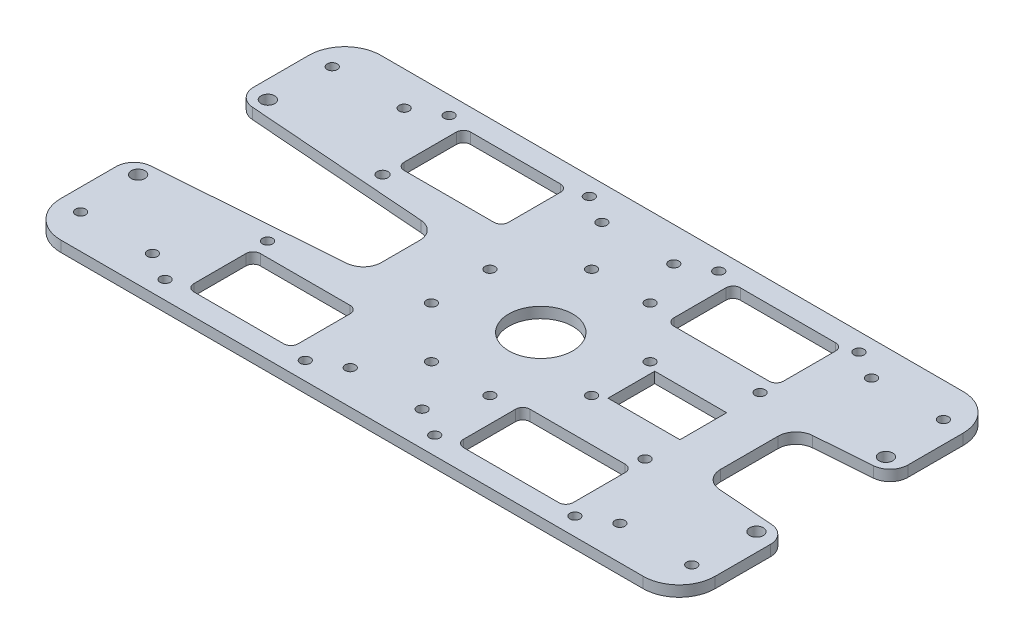
from build123d import *

# Parameters (mm, degrees)
SKETCH1_R           = 8.9
SKETCH1_R_2         = 1.9
SKETCH1_R_3         = 1.4
SKETCH1_R_4         = 1.5
SKETCH1_W           = 20
SKETCH1_H           = 13
BOSS_EXTRUDE1_DEPTH = 3


with BuildPart() as part:
    # Sketch1 → Boss-Extrude1 (new body)
    with BuildSketch(Plane(origin=(0, 0, 0), x_dir=(1, 0, 0), z_dir=(0, 1, 0))):
        with BuildLine():
            Line((78.373949741, -14.153046231), (62.626050259, -12.971953769))
            ThreePointArc((62.626050259, -12.971953769), (59.334638578, -11.386710908), (58, -7.98595722))
            Line((58, -7.98595722), (58, 7.98595722))
            ThreePointArc((58, 7.98595722), (59.334638578, 11.386710908), (62.626050259, 12.971953769))
            Line((62.626050259, 12.971953769), (78.373949741, 14.153046231))
            ThreePointArc((78.373949741, 14.153046231), (81.665361422, 15.738289092), (83, 19.13904278))
            Line((83, 19.13904278), (83, 34.5))
            ThreePointArc((83, 34.5), (80.071067812, 41.571067812), (73, 44.5))
            Line((73, 44.5), (-89, 44.5))
            ThreePointArc((-89, 44.5), (-96.071067812, 41.571067812), (-99, 34.5))
            Line((-99, 34.5), (-99, 19.13904278))
            ThreePointArc((-99, 19.13904278), (-97.665361422, 15.738289092), (-94.373949741, 14.153046231))
            Line((-94.373949741, 14.153046231), (-43.626050259, 10.346953769))
            ThreePointArc((-43.626050259, 10.346953769), (-40.334638578, 8.761710908), (-39, 5.36095722))
            Line((-39, 5.36095722), (-39, -5.36095722))
            ThreePointArc((-39, -5.36095722), (-40.334638578, -8.761710908), (-43.626050259, -10.346953769))
            Line((-43.626050259, -10.346953769), (-94.373949741, -14.153046231))
            ThreePointArc((-94.373949741, -14.153046231), (-97.665361422, -15.738289092), (-99, -19.13904278))
            Line((-99, -19.13904278), (-99, -34.5))
            ThreePointArc((-99, -34.5), (-96.071067812, -41.571067812), (-89, -44.5))
            Line((-89, -44.5), (73, -44.5))
            ThreePointArc((73, -44.5), (80.071067812, -41.571067812), (83, -34.5))
            Line((83, -34.5), (83, -19.13904278))
            ThreePointArc((83, -19.13904278), (81.665361422, -15.738289092), (78.373949741, -14.153046231))
        make_face()
        Circle(SKETCH1_R, mode=Mode.SUBTRACT)
        with Locations((78, -18)):
            Circle(SKETCH1_R_2, mode=Mode.SUBTRACT)
        with Locations((77, -35)):
            Circle(SKETCH1_R_3, mode=Mode.SUBTRACT)
        with Locations((57, -35)):
            Circle(SKETCH1_R_3, mode=Mode.SUBTRACT)
        with Locations((49, -39.5)):
            Circle(SKETCH1_R_3, mode=Mode.SUBTRACT)
        with Locations((45, -16)):
            Circle(SKETCH1_R_3, mode=Mode.SUBTRACT)
        with Locations((22.273863607, -8.131727984)):
            Circle(SKETCH1_R_3, mode=Mode.SUBTRACT)
        with Locations((22.273863607, 8.131727984)):
            Circle(SKETCH1_R_3, mode=Mode.SUBTRACT)
        with Locations((10, -39.5)):
            Circle(SKETCH1_R_3, mode=Mode.SUBTRACT)
        with Locations((2, -35)):
            Circle(SKETCH1_R_3, mode=Mode.SUBTRACT)
        with Locations((8.131727984, -22.273863607)):
            Circle(SKETCH1_R_3, mode=Mode.SUBTRACT)
        with Locations((-8.131727984, -22.273863607)):
            Circle(SKETCH1_R_3, mode=Mode.SUBTRACT)
        with Locations((-18, -35)):
            Circle(SKETCH1_R_3, mode=Mode.SUBTRACT)
        with Locations((-26, -39.5)):
            Circle(SKETCH1_R_3, mode=Mode.SUBTRACT)
        with Locations((-22.273863607, -8.131727984)):
            Circle(SKETCH1_R_3, mode=Mode.SUBTRACT)
        with Locations((-22.273863607, 8.131727984)):
            Circle(SKETCH1_R_3, mode=Mode.SUBTRACT)
        with Locations((-8.131727984, 22.273863607)):
            Circle(SKETCH1_R_3, mode=Mode.SUBTRACT)
        with Locations((8.131727984, 22.273863607)):
            Circle(SKETCH1_R_3, mode=Mode.SUBTRACT)
        with Locations((45, 16)):
            Circle(SKETCH1_R_3, mode=Mode.SUBTRACT)
        with Locations((78, 18)):
            Circle(SKETCH1_R_2, mode=Mode.SUBTRACT)
        with Locations((77, 35)):
            Circle(SKETCH1_R_3, mode=Mode.SUBTRACT)
        with Locations((57, 35)):
            Circle(SKETCH1_R_3, mode=Mode.SUBTRACT)
        with Locations((49, 39.5)):
            Circle(SKETCH1_R_3, mode=Mode.SUBTRACT)
        with Locations((10, 39.5)):
            Circle(SKETCH1_R_3, mode=Mode.SUBTRACT)
        with Locations((2, 35)):
            Circle(SKETCH1_R_3, mode=Mode.SUBTRACT)
        with Locations((-18, 35)):
            Circle(SKETCH1_R_3, mode=Mode.SUBTRACT)
        with Locations((-26, 39.5)):
            Circle(SKETCH1_R_3, mode=Mode.SUBTRACT)
        with Locations((-60, 16)):
            Circle(SKETCH1_R_4, mode=Mode.SUBTRACT)
        with Locations((-60, -16)):
            Circle(SKETCH1_R_3, mode=Mode.SUBTRACT)
        with Locations((-65, -39.5)):
            Circle(SKETCH1_R_3, mode=Mode.SUBTRACT)
        with Locations((-73, -35)):
            Circle(SKETCH1_R_3, mode=Mode.SUBTRACT)
        with Locations((-93, -35)):
            Circle(SKETCH1_R_3, mode=Mode.SUBTRACT)
        with Locations((-94, -18)):
            Circle(SKETCH1_R_2, mode=Mode.SUBTRACT)
        with Locations((-94, 18.096449674)):
            Circle(SKETCH1_R_2, mode=Mode.SUBTRACT)
        with Locations((-93, 35)):
            Circle(SKETCH1_R_3, mode=Mode.SUBTRACT)
        with Locations((-73, 35)):
            Circle(SKETCH1_R_3, mode=Mode.SUBTRACT)
        with Locations((-65, 39.5)):
            Circle(SKETCH1_R_3, mode=Mode.SUBTRACT)
        with BuildLine():
            Line((-33, 20), (-58, 20))
            ThreePointArc((-58, 20), (-59.414213562, 20.585786438), (-60, 22))
            Line((-60, 22), (-60, 36.5))
            ThreePointArc((-60, 36.5), (-59.414213562, 37.914213562), (-58, 38.5))
            Line((-58, 38.5), (-33, 38.5))
            ThreePointArc((-33, 38.5), (-31.585786438, 37.914213562), (-31, 36.5))
            Line((-31, 36.5), (-31, 22))
            ThreePointArc((-31, 22), (-31.585786438, 20.585786438), (-33, 20))
        make_face(mode=Mode.SUBTRACT)
        with Locations((35.205, 0)):
            Rectangle(SKETCH1_W, SKETCH1_H, mode=Mode.SUBTRACT)
        with BuildLine():
            Line((45.5, 36.5), (45.5, 22))
            ThreePointArc((45.5, 22), (44.914213562, 20.585786438), (43.5, 20))
            Line((43.5, 20), (17, 20))
            ThreePointArc((17, 20), (15.585786438, 20.585786438), (15, 22))
            Line((15, 22), (15, 36.5))
            ThreePointArc((15, 36.5), (15.585786438, 37.914213562), (17, 38.5))
            Line((17, 38.5), (43.5, 38.5))
            ThreePointArc((43.5, 38.5), (44.914213562, 37.914213562), (45.5, 36.5))
        make_face(mode=Mode.SUBTRACT)
        with BuildLine():
            Line((43.5, -38.5), (17, -38.5))
            ThreePointArc((17, -38.5), (15.585786438, -37.914213562), (15, -36.5))
            Line((15, -36.5), (15, -22))
            ThreePointArc((15, -22), (15.585786438, -20.585786438), (17, -20))
            Line((17, -20), (43.5, -20))
            ThreePointArc((43.5, -20), (44.914213562, -20.585786438), (45.5, -22))
            Line((45.5, -22), (45.5, -36.5))
            ThreePointArc((45.5, -36.5), (44.914213562, -37.914213562), (43.5, -38.5))
        make_face(mode=Mode.SUBTRACT)
        with BuildLine():
            Line((-31, -22), (-31, -36.5))
            ThreePointArc((-31, -36.5), (-31.585786438, -37.914213562), (-33, -38.5))
            Line((-33, -38.5), (-58, -38.5))
            ThreePointArc((-58, -38.5), (-59.414213562, -37.914213562), (-60, -36.5))
            Line((-60, -36.5), (-60, -22))
            ThreePointArc((-60, -22), (-59.414213562, -20.585786438), (-58, -20))
            Line((-58, -20), (-33, -20))
            ThreePointArc((-33, -20), (-31.585786438, -20.585786438), (-31, -22))
        make_face(mode=Mode.SUBTRACT)
    extrude(amount=BOSS_EXTRUDE1_DEPTH)


solid = part.part
